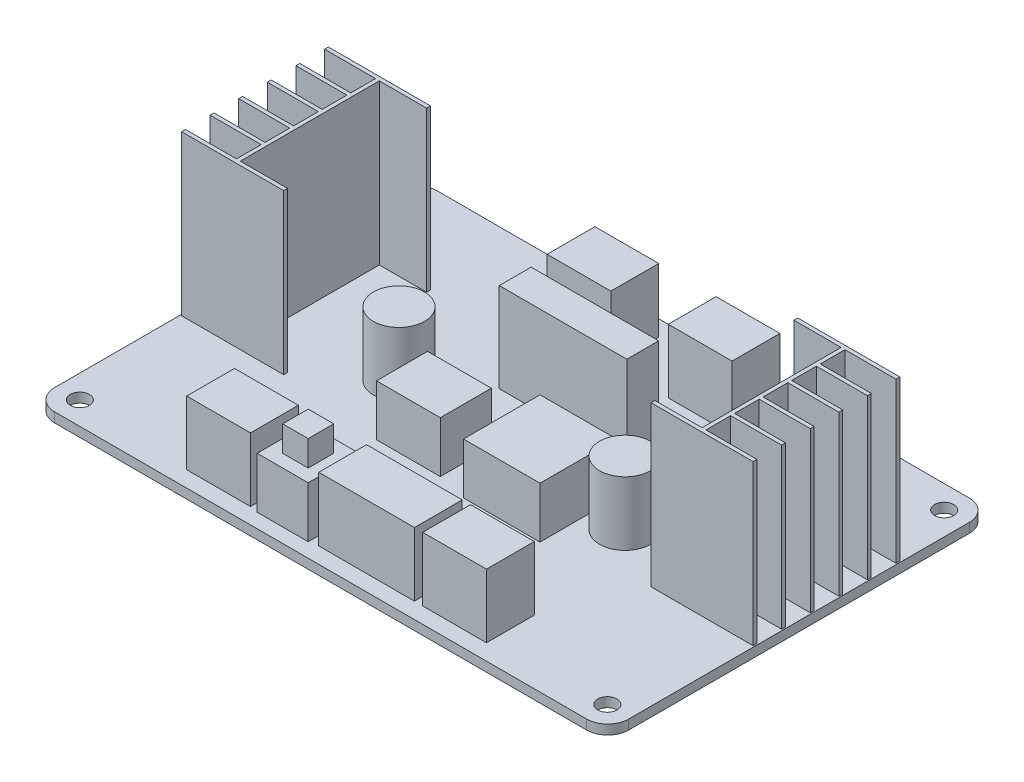
from build123d import *

# Parameters (mm, degrees)
SKETCH_1_R      = 1.5
EXTRUDE_1_DEPTH = 1.5
SKETCH_2_W      = 10
SKETCH_2_H      = 7.5
EXTRUDE_2_DEPTH = 10
SKETCH_3_W      = 8
SKETCH_3_H      = 8
EXTRUDE_3_DEPTH = 8
SKETCH_4_W      = 15
SKETCH_4_H      = 7.5
EXTRUDE_4_DEPTH = 10
EXTRUDE_5_DEPTH = 25
SKETCH_6_W      = 4
SKETCH_6_H      = 4
EXTRUDE_6_DEPTH = 4
SKETCH_7_W      = 20
SKETCH_7_H      = 5
EXTRUDE_7_DEPTH = 14
SKETCH_8_W      = 12
SKETCH_8_H      = 12
SKETCH_8_W_2    = 10
SKETCH_8_H_2    = 8
EXTRUDE_8_DEPTH = 8
SKETCH_9_R      = 4
EXTRUDE_9_DEPTH = 10


with BuildPart() as part:
    # 草图1 → 凸台-拉伸1 (new body)
    with BuildSketch(Plane(origin=(0, 0, 0), x_dir=(1, 0, 0), z_dir=(0, 1, 0))):
        with BuildLine():
            Line((-41.7, 30), (41.7, 30))
            ThreePointArc((41.7, 30), (44.033452378, 29.033452378), (45, 26.7))
            Line((45, 26.7), (45, -26.7))
            ThreePointArc((45, -26.7), (44.033452378, -29.033452378), (41.7, -30))
            Line((41.7, -30), (-41.7, -30))
            ThreePointArc((-41.7, -30), (-44.033452378, -29.033452378), (-45, -26.7))
            Line((-45, -26.7), (-45, 26.7))
            ThreePointArc((-45, 26.7), (-44.033452378, 29.033452378), (-41.7, 30))
        make_face()
        with Locations((-41.35, 26.4)):
            Circle(SKETCH_1_R, mode=Mode.SUBTRACT)
        with Locations((41.35, 26.4)):
            Circle(SKETCH_1_R, mode=Mode.SUBTRACT)
        with Locations((41.35, -26.4)):
            Circle(SKETCH_1_R, mode=Mode.SUBTRACT)
        with Locations((-41.35, -26.4)):
            Circle(SKETCH_1_R, mode=Mode.SUBTRACT)
    extrude(amount=EXTRUDE_1_DEPTH)

    # 草图2 → 凸台-拉伸2 (add)
    with BuildSketch(Plane(origin=(0, 1.5, 0), x_dir=(1, 0, 0), z_dir=(0, 1, 0))):
        with Locations((18.5, -23.75)):
            Rectangle(SKETCH_2_W, SKETCH_2_H)
        with Locations((-9.5, 23.75)):
            Rectangle(SKETCH_2_W, SKETCH_2_H)
        with Locations((9.5, 23.75)):
            Rectangle(SKETCH_2_W, SKETCH_2_H)
        with Locations((-18.5, -23.75)):
            Rectangle(SKETCH_2_W, SKETCH_2_H)
    extrude(amount=EXTRUDE_2_DEPTH)

    # 草图3 → 凸台-拉伸3 (add)
    with BuildSketch(Plane(origin=(0, 1.5, 0), x_dir=(1, 0, 0), z_dir=(0, 1, 0))):
        with Locations((-8.2, -23.75)):
            Rectangle(SKETCH_3_W, SKETCH_3_H)
    extrude(amount=EXTRUDE_3_DEPTH)

    # 草图4 → 凸台-拉伸4 (add)
    with BuildSketch(Plane(origin=(0, 1.5, 0), x_dir=(1, 0, 0), z_dir=(0, 1, 0))):
        with Locations((4.7, -23.75)):
            Rectangle(SKETCH_4_W, SKETCH_4_H)
    extrude(amount=EXTRUDE_4_DEPTH)

    # 草图5 → 凸台-拉伸5 (add)
    with BuildSketch(Plane(origin=(0, 1.5, 0), x_dir=(1, 0, 0), z_dir=(0, 1, 0))):
        Polygon((44.8, 16), (28.8, 16), (28.8, 15.4), (36.2, 15.4), (36.2, -6.4), (28.8, -6.4), (28.8, -7), (44.8, -7), (44.8, -6.4), (36.8, -6.4), (36.8, -2.52), (44.8, -2.52), (44.8, -1.92), (36.8, -1.92), (36.8, 1.96), (44.8, 1.96), (44.8, 2.56), (36.8, 2.56), (36.8, 6.44), (44.8, 6.44), (44.8, 7.04), (36.8, 7.04), (36.8, 10.92), (44.8, 10.92), (44.8, 11.52), (36.8, 11.52), (36.8, 15.4), (44.8, 15.4), align=None)
        Polygon((-44.8, 15.4), (-44.8, 16), (-28.8, 16), (-28.8, 15.4), (-36.2, 15.4), (-36.2, -6.4), (-28.8, -6.4), (-28.8, -7), (-44.8, -7), (-44.8, -6.4), (-36.8, -6.4), (-36.8, -2.52), (-44.8, -2.52), (-44.8, -1.92), (-36.8, -1.92), (-36.8, 1.96), (-44.8, 1.96), (-44.8, 2.56), (-36.8, 2.56), (-36.8, 6.44), (-44.8, 6.44), (-44.8, 7.04), (-36.8, 7.04), (-36.8, 10.92), (-44.8, 10.92), (-44.8, 11.52), (-36.8, 11.52), (-36.8, 15.4), align=None)
    extrude(amount=EXTRUDE_5_DEPTH)

    # 草图6 → 凸台-拉伸6 (add)
    with BuildSketch(Plane(origin=(0, 9.5, 0), x_dir=(1, 0, 0), z_dir=(0, 1, 0))):
        with Locations((-8.2, -23.75)):
            Rectangle(SKETCH_6_W, SKETCH_6_H)
    extrude(amount=EXTRUDE_6_DEPTH)

    # 草图7 → 凸台-拉伸7 (add)
    with BuildSketch(Plane(origin=(0, 1.5, 0), x_dir=(1, 0, 0), z_dir=(0, 1, 0))):
        with Locations((0, 10.5)):
            Rectangle(SKETCH_7_W, SKETCH_7_H)
    extrude(amount=EXTRUDE_7_DEPTH)

    # 草图8 → 凸台-拉伸8 (add)
    with BuildSketch(Plane(origin=(0, 1.5, 0), x_dir=(1, 0, 0), z_dir=(0, 1, 0))):
        with Locations((8.02497304, -3.633209752)):
            Rectangle(SKETCH_8_W, SKETCH_8_H)
        with Locations((-7.684380811, -4.555618829)):
            Rectangle(SKETCH_8_W_2, SKETCH_8_H_2)
    extrude(amount=EXTRUDE_8_DEPTH)

    # 草图9 → 凸台-拉伸9 (add)
    with BuildSketch(Plane(origin=(0, 1.5, 0), x_dir=(1, 0, 0), z_dir=(0, 1, 0))):
        with Locations((-19, 1.275195949)):
            Circle(SKETCH_9_R)
        with Locations((19, -1.275195949)):
            Circle(SKETCH_9_R)
    extrude(amount=EXTRUDE_9_DEPTH)


solid = part.part
